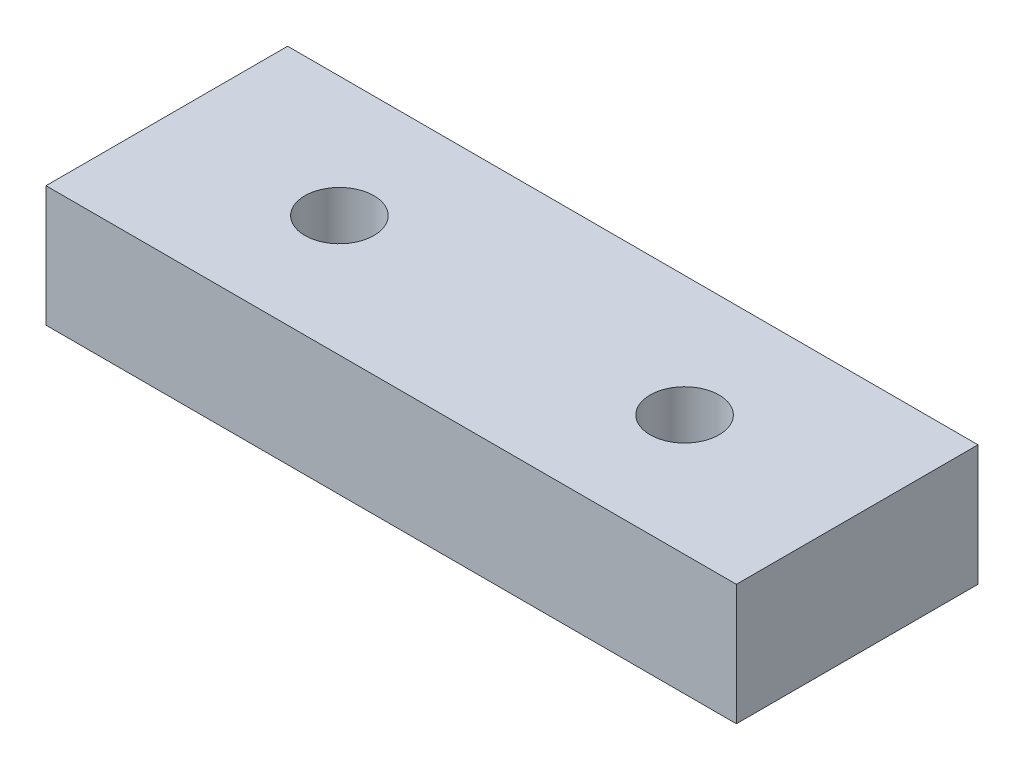
from build123d import *

# Parameters (mm, degrees)
CROQUIS1_W              = 20
CROQUIS1_H              = 7
CROQUIS1_R              = 1
SALIENTE_EXTRUIR1_DEPTH = 3.5


with BuildPart() as part:
    # Croquis1 → Saliente-Extruir1 (new body)
    with BuildSketch(Plane(origin=(0, 0, 0), x_dir=(1, 0, 0), z_dir=(0, 1, 0))):
        with Locations((10, 3.5)):
            Rectangle(CROQUIS1_W, CROQUIS1_H)
        with Locations((5, 3.5)):
            Circle(CROQUIS1_R, mode=Mode.SUBTRACT)
        with Locations((15, 3.5)):
            Circle(CROQUIS1_R, mode=Mode.SUBTRACT)
    extrude(amount=SALIENTE_EXTRUIR1_DEPTH)


solid = part.part
